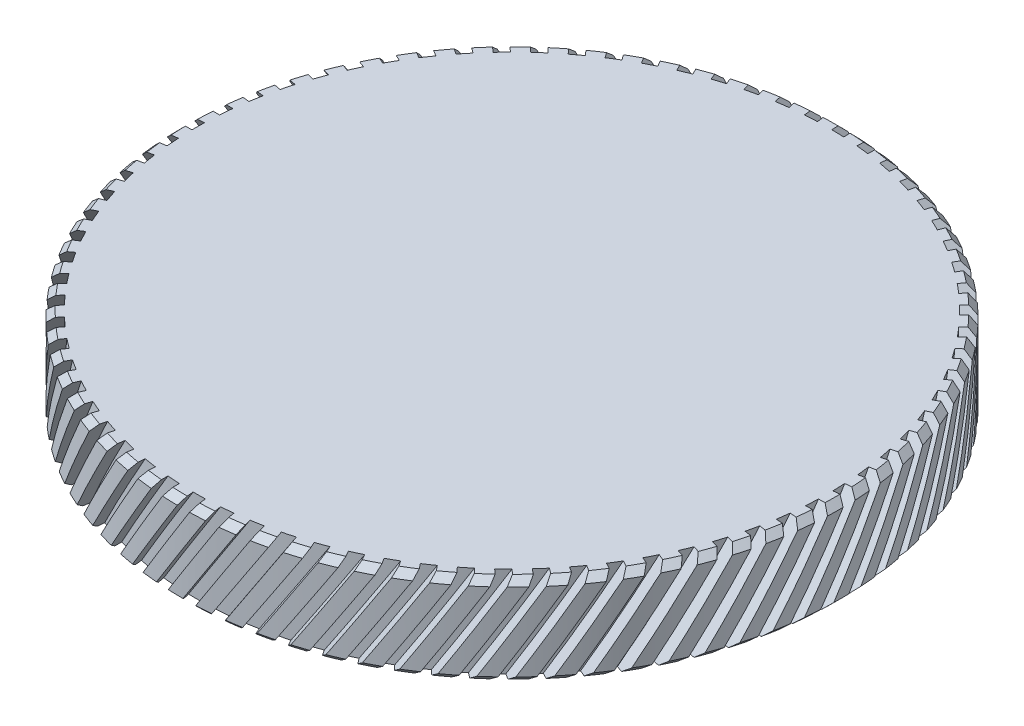
from build123d import *

# Parameters (mm, degrees)
CHAMFER_1_SIZE           = 0.5
CUT_EXTRUDE_1_REACH      = 70.315
CUT_EXTRUDE_1_END_RADIUS = 24.4
CUT_EXTRUDE_START        = 30
PATTERN_CIRCULAR_1_COUNT = 75


with BuildPart() as part:
    # 草图1 → 旋转1 (revolve)
    with BuildSketch(Plane.XY, mode=Mode.PRIVATE) as revolve_1_sk:
        Polygon((20.5, -8.830884482), (21.1, -8.830884482), (21.1, -7.830884482), (0, -7.830884482), (0, -6.330884482), (25.4, -6.330884482), (25.4, -13.330884482), (20.5, -13.330884482), align=None)
    revolve(revolve_1_sk.sketch.rotate(Axis((0, 46.02073106, 0), (0, -1, 0)), 90), axis=Axis((0, 46.02073106, 0), (0, -1, 0)))

    # 倒角1
    chamfer_1_edges = [part.edges().sort_by_distance(p)[0] for p in [
        (0, -6.330884482, -25.4),
        (0, -13.330884482, -25.4),
    ]]
    chamfer(chamfer_1_edges, length=CHAMFER_1_SIZE)

    # 切除-拉伸1: up to this cylinder (the profile starts outside it)
    cut_extrude_1_end = Plane(origin=(0, -8.265312, 0), z_dir=(0, 1, 0)) * Cylinder(CUT_EXTRUDE_1_END_RADIUS, 190.43, mode=Mode.PRIVATE)
    # 草图2 → 切除-拉伸1 (cut, up to the surface)
    with BuildSketch(Plane.XY.offset(CUT_EXTRUDE_START), mode=Mode.PRIVATE) as cut_extrude_1_sk1:
        Polygon((0, -2.775948505), (-6.592317224, -13.330884482), (-5.913788084, -13.754674768), (0.67852914, -3.199738791), align=None)
    cut_extrude_1_tool1 = extrude(cut_extrude_1_sk1.sketch, amount=-CUT_EXTRUDE_1_REACH, mode=Mode.PRIVATE) - cut_extrude_1_end
    cut_extrude_1 = cut_extrude_1_tool1.solids().sort_by_distance((-2.956894, -8.265312, 30))[0]
    add(cut_extrude_1, mode=Mode.SUBTRACT)

    # 阵列(圆周)1: 切除-拉伸1 ×75 about axis
    pattern_circular_1_axis = Axis((0, 0, 0), (0, 1, 0))
    for i in range(1, PATTERN_CIRCULAR_1_COUNT):
        add(cut_extrude_1.rotate(pattern_circular_1_axis, i * 360 / PATTERN_CIRCULAR_1_COUNT), mode=Mode.SUBTRACT)


solid = part.part
